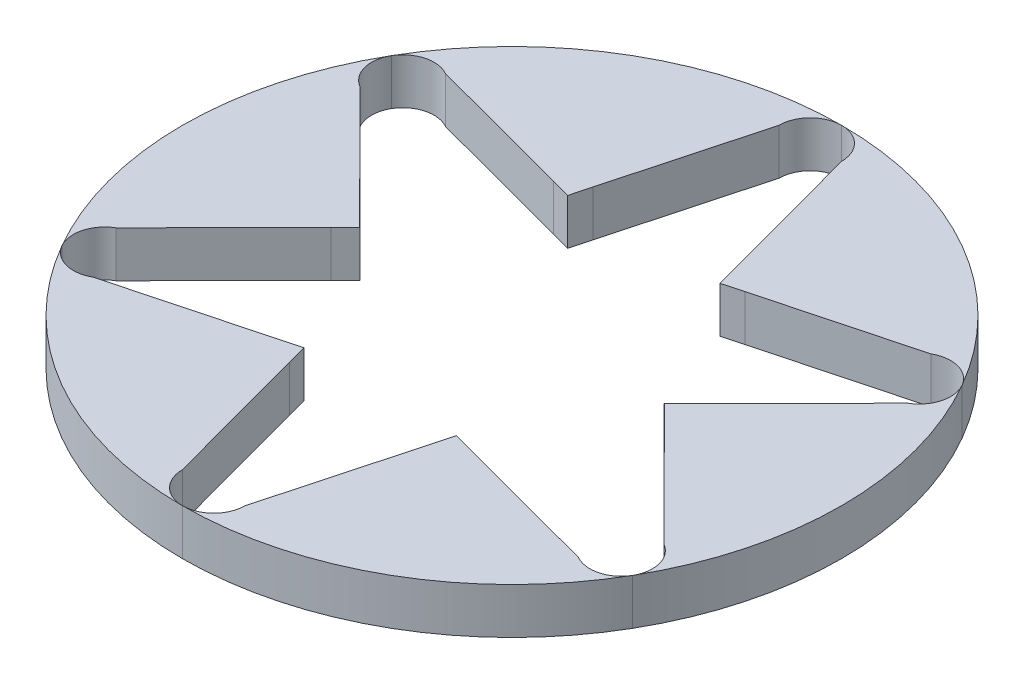
from build123d import *

# Parameters (mm, degrees)
SKETCH_1_R          = 15.8
EXTRUDE_1_DEPTH     = 2.2
CUT_EXTRUDE_2_DEPTH = 2.2


with BuildPart() as part:
    # 草圖1 → 填料-伸長1 (new body)
    with BuildSketch(Plane(origin=(0, 0, 0), x_dir=(1, 0, 0), z_dir=(0, 1, 0))):
        Circle(SKETCH_1_R)
    extrude(amount=EXTRUDE_1_DEPTH)

    # 草圖3 → 除料-伸長2 (cut)
    with BuildSketch(Plane.XZ):
        with BuildLine():
            Line((-1.5, 14.3), (-3.4, 7.272575881))
            Line((-3.4, 7.272575881), (-3.650072203, 6.322110506))
            Line((-3.650072203, 6.322110506), (-4.598235464, 6.580774314))
            Line((-4.598235464, 6.580774314), (-11.634163274, 8.449038106))
            ThreePointArc((-11.634163274, 8.449038106), (-12.772391842, 8.598888739), (-13.68320138, 7.9))
            ThreePointArc((-13.68320138, 7.9), (-13.833052014, 6.761771432), (-13.134163274, 5.850961894))
            Line((-13.134163274, 5.850961894), (-7.998235464, 0.691801568))
            Line((-7.998235464, 0.691801568), (-7.300144405, 0))
            Line((-7.300144405, 0), (-7.998235464, -0.691801568))
            Line((-7.998235464, -0.691801568), (-13.134163274, -5.850961894))
            ThreePointArc((-13.134163274, -5.850961894), (-13.833052014, -6.761771432), (-13.68320138, -7.9))
            ThreePointArc((-13.68320138, -7.9), (-12.772391842, -8.598888739), (-11.634163274, -8.449038106))
            Line((-11.634163274, -8.449038106), (-4.598235464, -6.580774314))
            Line((-4.598235464, -6.580774314), (-3.650072203, -6.322110506))
            Line((-3.650072203, -6.322110506), (-3.4, -7.272575881))
            Line((-3.4, -7.272575881), (-1.5, -14.3))
            ThreePointArc((-1.5, -14.3), (-1.060660172, -15.360660172), (0, -15.8))
            ThreePointArc((0, -15.8), (1.060660172, -15.360660172), (1.5, -14.3))
            Line((1.5, -14.3), (3.4, -7.272575881))
            Line((3.4, -7.272575881), (3.650072203, -6.322110506))
            Line((3.650072203, -6.322110506), (4.598235464, -6.580774314))
            Line((4.598235464, -6.580774314), (11.634163274, -8.449038106))
            ThreePointArc((11.634163274, -8.449038106), (12.772391842, -8.598888739), (13.68320138, -7.9))
            ThreePointArc((13.68320138, -7.9), (13.833052014, -6.761771432), (13.134163274, -5.850961894))
            Line((13.134163274, -5.850961894), (7.998235464, -0.691801568))
            Line((7.998235464, -0.691801568), (7.300144405, 0))
            Line((7.300144405, 0), (7.998235464, 0.691801568))
            Line((7.998235464, 0.691801568), (13.134163274, 5.850961894))
            ThreePointArc((13.134163274, 5.850961894), (13.833052014, 6.761771432), (13.68320138, 7.9))
            ThreePointArc((13.68320138, 7.9), (12.772391842, 8.598888739), (11.634163274, 8.449038106))
            Line((11.634163274, 8.449038106), (4.598235464, 6.580774314))
            Line((4.598235464, 6.580774314), (3.650072203, 6.322110506))
            Line((3.650072203, 6.322110506), (3.4, 7.272575881))
            Line((3.4, 7.272575881), (1.5, 14.3))
            ThreePointArc((1.5, 14.3), (1.060660172, 15.360660172), (0, 15.8))
            ThreePointArc((0, 15.8), (-1.060660172, 15.360660172), (-1.5, 14.3))
        make_face()
    extrude(amount=-CUT_EXTRUDE_2_DEPTH, mode=Mode.SUBTRACT)


solid = part.part
